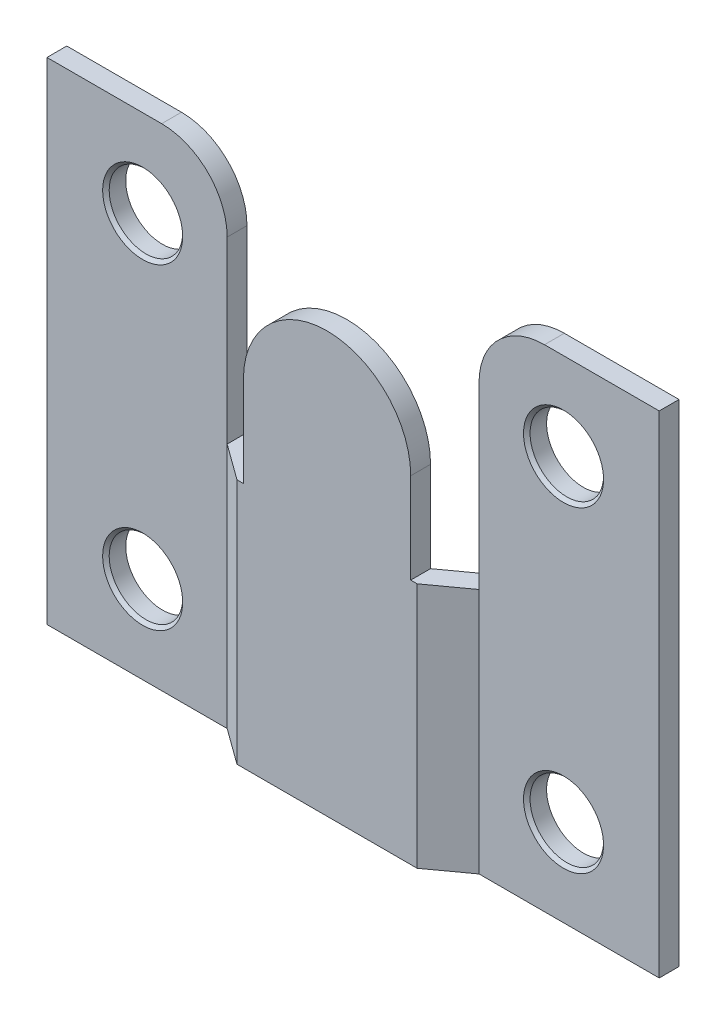
from build123d import *

# Parameters (mm, degrees)
BOSS_EXTRUDE1_DEPTH     = 38.1
CUT_EXTRUDE2_DEPTH      = 18.9865
CUT_EXTRUDE4_DEPTH      = 3.0193
CUT_EXTRUDE4_DEPTH_BACK = 2.5367
FILLET3_R               = 5.08
SKETCH8_R               = 2.85115
CUT_EXTRUDE5_DEPTH      = 3.0193
CUT_EXTRUDE5_DEPTH_BACK = 2.5367
CHAMFER1_SIZE           = 0.254


with BuildPart() as part:
    # Sketch1 → Boss-Extrude1 (new body)
    with BuildSketch(Plane(origin=(0, 0, 0), x_dir=(1, 0, 0), z_dir=(0, 1, 0))):
        Polygon((9.770109876, 2.0193), (6.989445062, 0), (-6.989445062, 0), (-9.770109876, 2.0193), (-23.749, 2.0193), (-23.749, 3.556), (-9.271, 3.556), (-6.490335186, 1.5367), (6.490335186, 1.5367), (9.271, 3.556), (23.749, 3.556), (23.749, 2.0193), align=None)
    extrude(amount=BOSS_EXTRUDE1_DEPTH)

    # Sketch3 → Cut-Extrude2 (cut)
    with BuildSketch(Plane(origin=(0, 38.1, 0), x_dir=(1, 0, 0), z_dir=(0, 1, 0))):
        Polygon((-9.770109876, 3.91845022), (-9.770109876, 2.0193), (-6.490335186, -0.36245022), (-6.490335186, 1.5367), align=None)
        Polygon((6.490335186, 1.5367), (9.770109876, 3.91845022), (9.770109876, 2.0193), (6.490335186, -0.36245022), align=None)
    extrude(amount=-CUT_EXTRUDE2_DEPTH, mode=Mode.SUBTRACT)

    # Sketch6 → Cut-Extrude4 (cut, two sides)
    with BuildSketch(Plane(origin=(0, 0, -1.5367), x_dir=(-1, 0, 0), z_dir=(0, 0, -1))) as cut_extrude4_sk:
        with BuildLine():
            Line((-6.490335186, 26.123264814), (-8.408477538, 26.123264814))
            Line((-8.408477538, 26.123264814), (-8.408477538, 40.625106564))
            Line((-8.408477538, 40.625106564), (8.313468388, 40.625106564))
            Line((8.313468388, 40.625106564), (8.313468388, 26.123264814))
            Line((8.313468388, 26.123264814), (6.490335186, 26.123264814))
            ThreePointArc((6.490335186, 26.123264814), (0, 32.6136), (-6.490335186, 26.123264814))
        make_face()
    extrude(amount=CUT_EXTRUDE4_DEPTH, mode=Mode.SUBTRACT)
    extrude(cut_extrude4_sk.sketch, amount=-CUT_EXTRUDE4_DEPTH_BACK, mode=Mode.SUBTRACT)

    # Fillet3
    fillet3_edges = [part.edges().sort_by_distance(p)[0] for p in [
        (-9.770109876, 38.1, -2.78765),
        (9.770109876, 38.1, -2.78765),
    ]]
    fillet(fillet3_edges, radius=FILLET3_R)

    # Sketch8 → Cut-Extrude5 (cut, two sides)
    with BuildSketch(Plane.XY.offset(-2.0193)) as cut_extrude5_sk:
        with Locations((-16.32585, 31.33725)):
            Circle(SKETCH8_R)
        with Locations((-16.32585, 6.76275)):
            Circle(SKETCH8_R)
        with Locations((16.32585, 6.76275)):
            Circle(SKETCH8_R)
        with Locations((16.32585, 31.33725)):
            Circle(SKETCH8_R)
    extrude(amount=CUT_EXTRUDE5_DEPTH, mode=Mode.SUBTRACT)
    extrude(cut_extrude5_sk.sketch, amount=-CUT_EXTRUDE5_DEPTH_BACK, mode=Mode.SUBTRACT)

    # Chamfer1
    chamfer1_edges = [part.edges().sort_by_distance(p)[0] for p in [
        (-19.177, 31.33725, -2.0193),
        (-19.177, 6.76275, -2.0193),
        (13.4747, 6.76275, -2.0193),
        (13.4747, 31.33725, -2.0193),
    ]]
    chamfer(chamfer1_edges, length=CHAMFER1_SIZE)


solid = part.part
